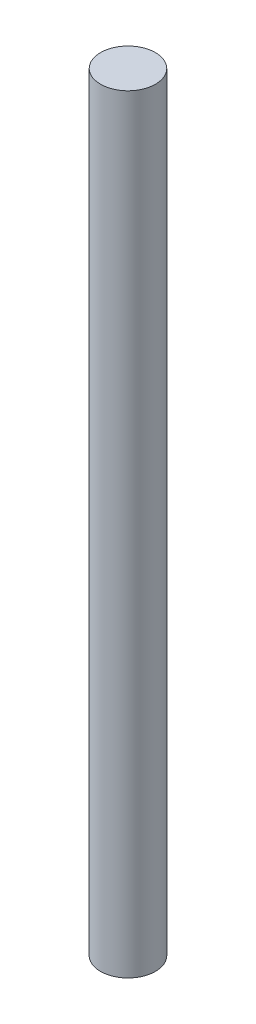
from build123d import *

# Parameters (mm, degrees)
SKETCH1_R           = 6.35
BOSS_EXTRUDE1_DEPTH = 177.8


with BuildPart() as part:
    # Sketch1 → Boss-Extrude1 (new body)
    with BuildSketch(Plane(origin=(0, 0, 0), x_dir=(1, 0, 0), z_dir=(0, 1, 0))):
        Circle(SKETCH1_R)
    extrude(amount=BOSS_EXTRUDE1_DEPTH)


solid = part.part
